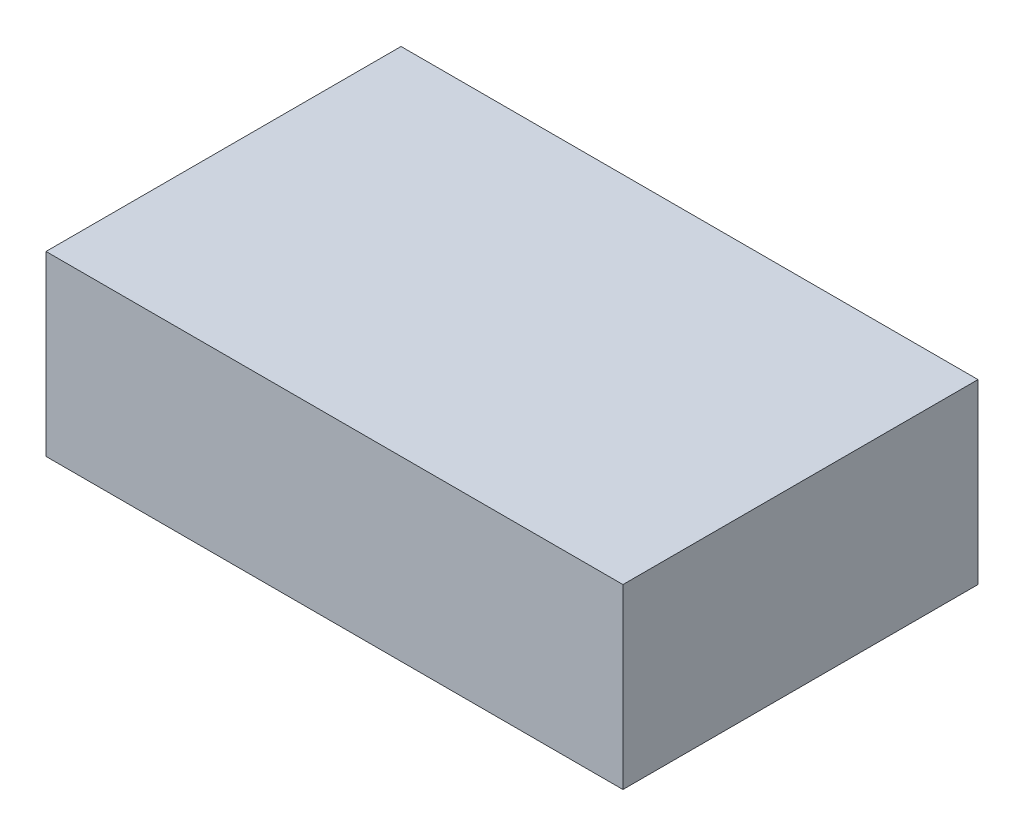
from build123d import *

# Parameters (mm, degrees)
SKETCH1_W           = 1.3
SKETCH1_H           = 0.8
BOSS_EXTRUDE1_DEPTH = 0.4


with BuildPart() as part:
    # Sketch1 → Boss-Extrude1 (new body)
    with BuildSketch(Plane(origin=(0, 0, 0), x_dir=(1, 0, 0), z_dir=(0, 1, 0))):
        with Locations((0.65, 0.4)):
            Rectangle(SKETCH1_W, SKETCH1_H)
    extrude(amount=BOSS_EXTRUDE1_DEPTH)


solid = part.part
